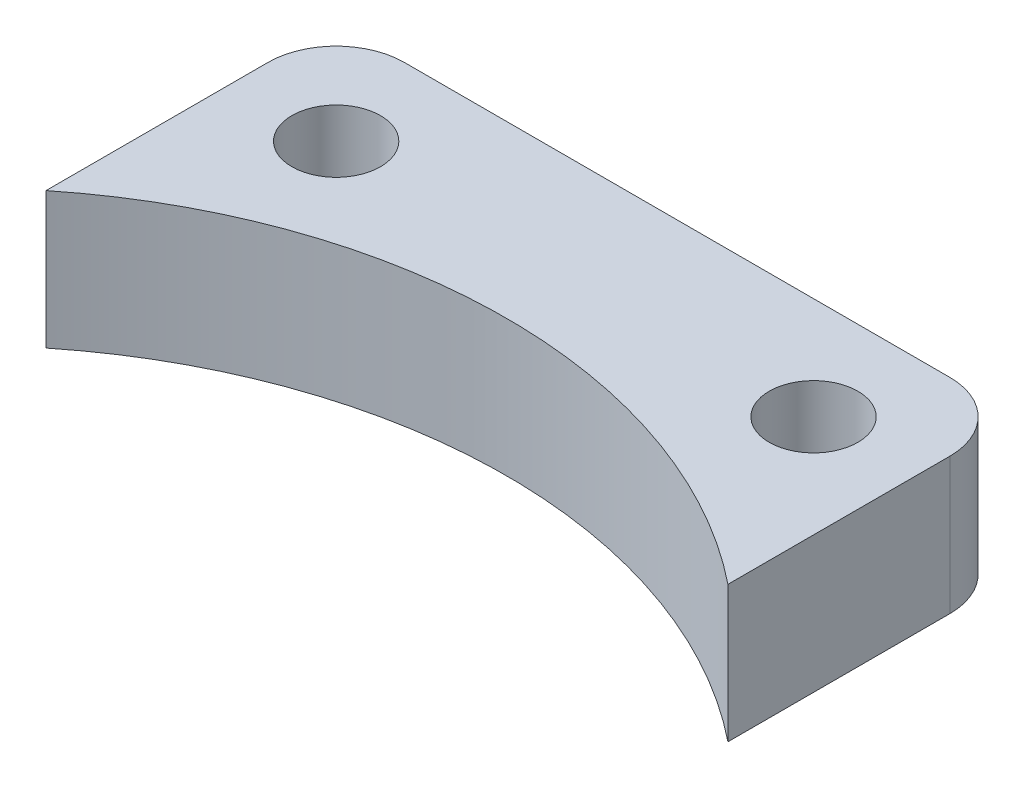
from build123d import *

# Parameters (mm, degrees)
BOSS_EXTRU_1_DEPTH      = 10
CONG_1_R                = 5
ESQUISSE3_R             = 3.25
ENL_V_MAT_EXTRU_1_DEPTH = 11


with BuildPart() as part:
    # Esquisse1 → Boss.-Extru.1 (new body)
    with BuildSketch(Plane(origin=(0, 0, 0), x_dir=(1, 0, 0), z_dir=(0, 1, 0))):
        with BuildLine():
            Line((25, 31.224989992), (25, 52.5))
            Line((25, 52.5), (-25, 52.5))
            Line((-25, 52.5), (-25, 31.224989992))
            ThreePointArc((-25, 31.224989992), (0, 40), (25, 31.224989992))
        make_face()
    extrude(amount=BOSS_EXTRU_1_DEPTH)

    # Congé1
    cong_1_edges = [part.edges().sort_by_distance(p)[0] for p in [
        (-25, 5, -52.5),
        (25, 5, -52.5),
    ]]
    fillet(cong_1_edges, radius=CONG_1_R)

    # Esquisse3 → Enlèv. mat.-Extru.1 (cut, through all)
    with BuildSketch(Plane(origin=(0, 10, 0), x_dir=(1, 0, 0), z_dir=(0, 1, 0))):
        with Locations(Location((-17.5, 45, 0), (0, 0, 270))):  # turned: the seam where the file's is
            Circle(ESQUISSE3_R)
        with Locations(Location((17.5, 45, 0), (0, 0, 270))):  # turned: the seam where the file's is
            Circle(ESQUISSE3_R)
    extrude(amount=-ENL_V_MAT_EXTRU_1_DEPTH, mode=Mode.SUBTRACT)


solid = part.part
